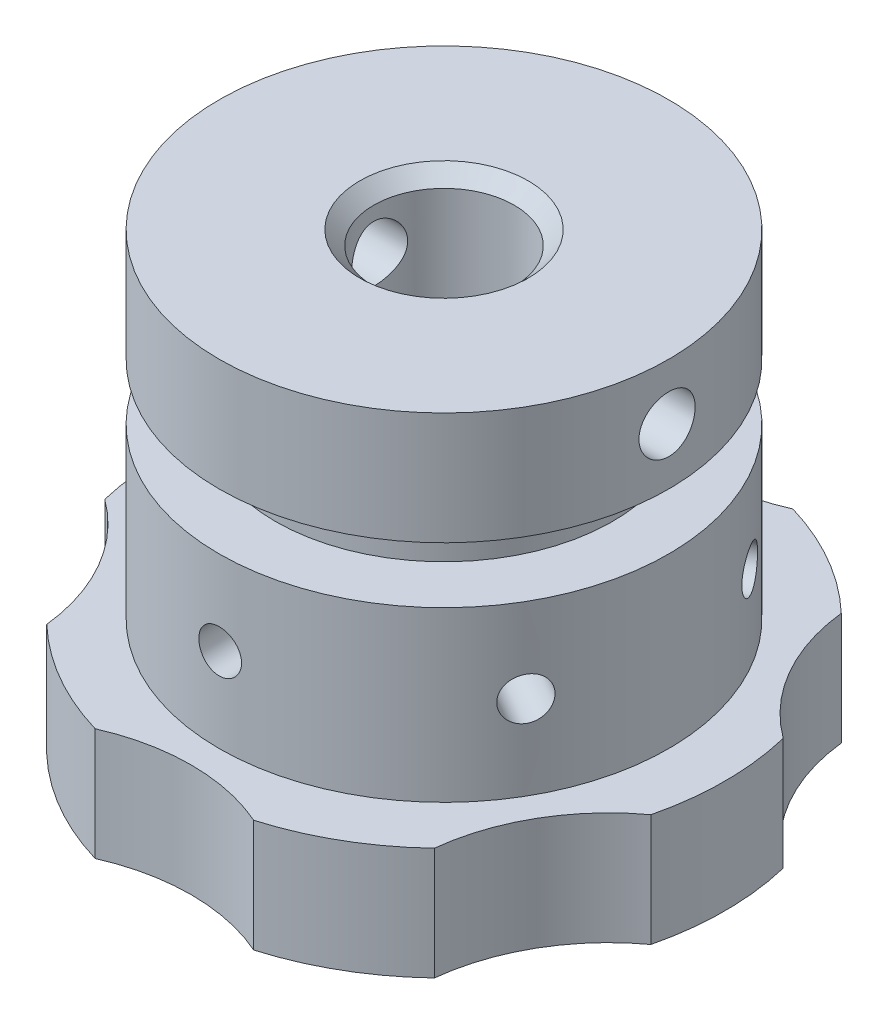
from build123d import *

# Parameters (mm, degrees)
CUT_EXTRUDE1_REACH = 103.6
CUT_EXTRUDE2_REACH = 103.6
SKETCH3_R          = 15.875
CHAMFER1_SIZE      = 3.175
SKETCH4_R          = 6.35
CUT_EXTRUDE3_DEPTH = 50.8
SKETCH5_R          = 4.826
CUT_EXTRUDE4_DEPTH = 50.8
CIRPATTERN1_COUNT  = 6


with BuildPart() as part:
    # Sketch1 → Revolve1 (revolve)
    with BuildSketch(Plane.XY):
        Polygon((0, 0), (50.8, 0), (50.8, -25.4), (38.1, -25.4), (38.1, -38.1), (50.8, -38.1), (50.8, -76.2), (63.5, -76.2), (63.5, -101.6), (0, -101.6), align=None)
    revolve(axis=Axis((0, 0, 0), (0, -1, 0)))

    # Sketch2 → Cut-Extrude1 (cut, up to next)
    with BuildSketch(Plane.XZ.offset(101.6), mode=Mode.PRIVATE) as cut_extrude1_sk1:
        with BuildLine():
            ThreePointArc((-17.915510735, 60.9203125), (0, 57.15), (17.915510735, 60.9203125))
            ThreePointArc((17.915510735, 60.9203125), (0, 63.5), (-17.915510735, 60.9203125))
        make_face()
    cut_extrude1_tool1 = extrude(cut_extrude1_sk1.sketch, amount=-CUT_EXTRUDE1_REACH, mode=Mode.PRIVATE) & part.part
    add(cut_extrude1_tool1.solids().sort_by_distance((0, -101.6, 60.438615))[0], mode=Mode.SUBTRACT)
    # Sketch2 → Cut-Extrude1 (cut, up to next)
    with BuildSketch(Plane.XZ.offset(101.6), mode=Mode.PRIVATE) as cut_extrude1_sk2:
        with BuildLine():
            ThreePointArc((-43.800782864, 45.975443668), (-54.99261314, 31.75), (-61.716293599, 14.944868832))
            ThreePointArc((-61.716293599, 14.944868832), (-49.493351826, 28.575), (-43.800782864, 45.975443668))
        make_face()
    cut_extrude1_tool2 = extrude(cut_extrude1_sk2.sketch, amount=-CUT_EXTRUDE1_REACH, mode=Mode.PRIVATE) & part.part
    add(cut_extrude1_tool2.solids().sort_by_distance((-52.341376, -101.6, 30.219308))[0], mode=Mode.SUBTRACT)
    # Sketch2 → Cut-Extrude1 (cut, up to next)
    with BuildSketch(Plane.XZ.offset(101.6), mode=Mode.PRIVATE) as cut_extrude1_sk3:
        with BuildLine():
            ThreePointArc((43.800782864, 45.975443668), (49.493351826, 28.575), (61.716293599, 14.944868832))
            ThreePointArc((61.716293599, 14.944868832), (54.99261314, 31.75), (43.800782864, 45.975443668))
        make_face()
    cut_extrude1_tool3 = extrude(cut_extrude1_sk3.sketch, amount=-CUT_EXTRUDE1_REACH, mode=Mode.PRIVATE) & part.part
    add(cut_extrude1_tool3.solids().sort_by_distance((52.341376, -101.6, 30.219308))[0], mode=Mode.SUBTRACT)
    # Sketch2 → Cut-Extrude1 (cut, up to next)
    with BuildSketch(Plane.XZ.offset(101.6), mode=Mode.PRIVATE) as cut_extrude1_sk4:
        with BuildLine():
            ThreePointArc((61.716293599, -14.944868832), (49.493351826, -28.575), (43.800782864, -45.975443668))
            ThreePointArc((43.800782864, -45.975443668), (54.99261314, -31.75), (61.716293599, -14.944868832))
        make_face()
    cut_extrude1_tool4 = extrude(cut_extrude1_sk4.sketch, amount=-CUT_EXTRUDE1_REACH, mode=Mode.PRIVATE) & part.part
    add(cut_extrude1_tool4.solids().sort_by_distance((52.341376, -101.6, -30.219308))[0], mode=Mode.SUBTRACT)
    # Sketch2 → Cut-Extrude1 (cut, up to next)
    with BuildSketch(Plane.XZ.offset(101.6), mode=Mode.PRIVATE) as cut_extrude1_sk5:
        with BuildLine():
            ThreePointArc((17.915510735, -60.9203125), (0, -57.15), (-17.915510735, -60.9203125))
            ThreePointArc((-17.915510735, -60.9203125), (0, -63.5), (17.915510735, -60.9203125))
        make_face()
    cut_extrude1_tool5 = extrude(cut_extrude1_sk5.sketch, amount=-CUT_EXTRUDE1_REACH, mode=Mode.PRIVATE) & part.part
    add(cut_extrude1_tool5.solids().sort_by_distance((0, -101.6, -60.438615))[0], mode=Mode.SUBTRACT)
    # Sketch2 → Cut-Extrude1 (cut, up to next)
    with BuildSketch(Plane.XZ.offset(101.6), mode=Mode.PRIVATE) as cut_extrude1_sk6:
        with BuildLine():
            ThreePointArc((-43.800782864, -45.975443668), (-49.493351826, -28.575), (-61.716293599, -14.944868832))
            ThreePointArc((-61.716293599, -14.944868832), (-54.99261314, -31.75), (-43.800782864, -45.975443668))
        make_face()
    cut_extrude1_tool6 = extrude(cut_extrude1_sk6.sketch, amount=-CUT_EXTRUDE1_REACH, mode=Mode.PRIVATE) & part.part
    add(cut_extrude1_tool6.solids().sort_by_distance((-52.341376, -101.6, -30.219308))[0], mode=Mode.SUBTRACT)

    # Sketch3 → Cut-Extrude2 (cut, up to next)
    with BuildSketch(Plane(origin=(0, 0, 0), x_dir=(1, 0, 0), z_dir=(0, 1, 0)), mode=Mode.PRIVATE) as cut_extrude2_sk1:
        Circle(SKETCH3_R)
    cut_extrude2_tool1 = extrude(cut_extrude2_sk1.sketch, amount=-CUT_EXTRUDE2_REACH, mode=Mode.PRIVATE) & part.part
    add(cut_extrude2_tool1.solids().sort_by_distance((0, 0, 0))[0], mode=Mode.SUBTRACT)

    # Chamfer1
    chamfer1_edges = [part.edges().sort_by_distance(p)[0] for p in [
        (-15.875, 0, 0),
    ]]
    chamfer(chamfer1_edges, length=CHAMFER1_SIZE)

    # Sketch4 → Cut-Extrude3 (cut, symmetric)
    with BuildSketch(Plane(origin=(0, 0, 0), x_dir=(0, 0, -1), z_dir=(1, 0, 0))):
        with Locations((0, -12.7)):
            Circle(SKETCH4_R)
    extrude(amount=CUT_EXTRUDE3_DEPTH, both=True, mode=Mode.SUBTRACT)

    # Sketch5 → Cut-Extrude4 (cut, symmetric)
    with BuildSketch(Plane.XY):
        with Locations((0, -57.15)):
            Circle(SKETCH5_R)
    cut_extrude4 = extrude(amount=CUT_EXTRUDE4_DEPTH, both=True, mode=Mode.SUBTRACT)

    # CirPattern1: Cut-Extrude4 ×6 about axis
    cirpattern1_axis = Axis((0, -38.1, 0), (0, 1, 0))
    for i in range(1, CIRPATTERN1_COUNT):
        add(cut_extrude4.rotate(cirpattern1_axis, i * 360 / CIRPATTERN1_COUNT), mode=Mode.SUBTRACT)


solid = part.part
